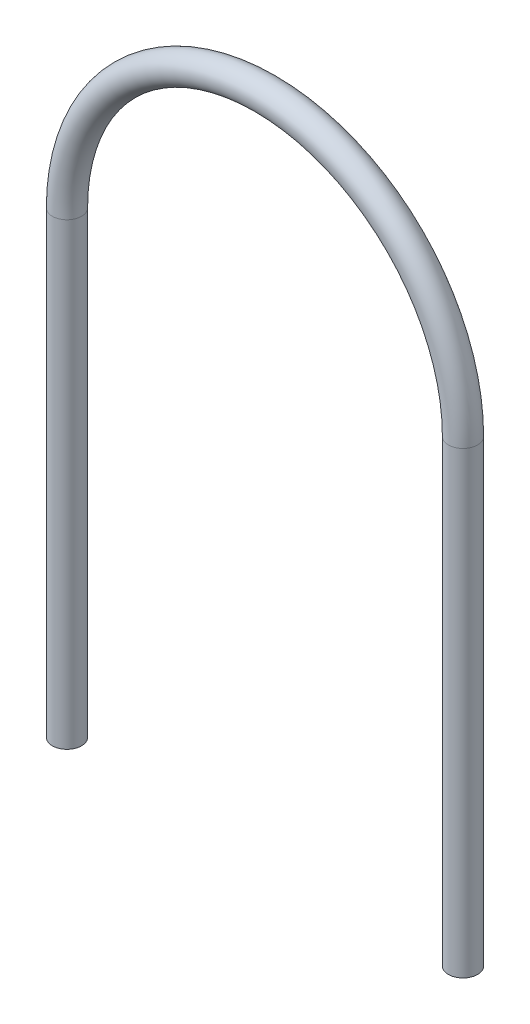
from build123d import *

# Parameters (mm, degrees)
SKETCH2_R = 2.0193


with BuildPart() as part:
    # Sweep3: sweep along a path in Sketch1
    with BuildLine(Plane.XY) as sweep3_path:
        Line((0, 0), (0, 63.5))
        ThreePointArc((0, 63.5), (27.4193, 90.9193), (54.8386, 63.5))
        Line((54.8386, 63.5), (54.8386, 0))
    # Sketch2 → Sweep3 (sweep)
    with BuildSketch(Plane(origin=(0, 0, 0), x_dir=(1, 0, 0), z_dir=(0, 1, 0))):
        Circle(SKETCH2_R)
    sweep(path=sweep3_path.line)


solid = part.part
